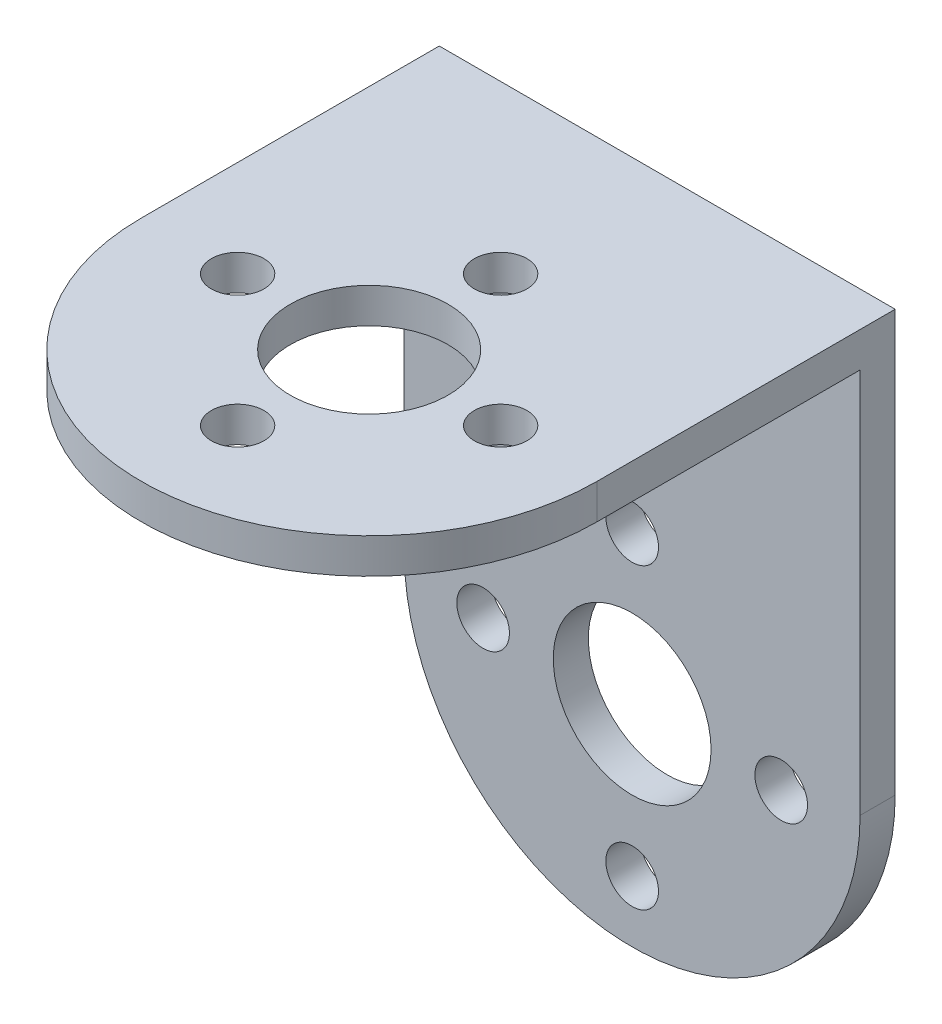
from build123d import *

# Parameters (mm, degrees)
BOSS_EXTRUDE1_DEPTH = 26
SKETCH4_R           = 4.5
SKETCH4_R_2         = 1.5
CUT_EXTRUDE2_DEPTH  = 3
SKETCH5_R           = 1.5
SKETCH5_R_2         = 4.5
CUT_EXTRUDE3_DEPTH  = 3


with BuildPart() as part:
    # Sketch2 → Boss-Extrude1 (new body)
    with BuildSketch(Plane(origin=(0, 0, 0), x_dir=(0, 0, -1), z_dir=(1, 0, 0))):
        Polygon((-15.5, 1), (14.5, 1), (14.5, -36), (12.5, -36), (12.5, -1), (-15.5, -1), align=None)
    extrude(amount=BOSS_EXTRUDE1_DEPTH)

    # Sketch4 → Cut-Extrude2 (cut, through all)
    with BuildSketch(Plane.XY.offset(-12.5)):
        with Locations((13, -24)):
            Circle(SKETCH4_R)
        with Locations((4.5, -24)):
            Circle(SKETCH4_R_2)
        with Locations((13, -32.5)):
            Circle(SKETCH4_R_2)
        with Locations((21.5, -24)):
            Circle(SKETCH4_R_2)
        with Locations((13, -15.5)):
            Circle(SKETCH4_R_2)
        with BuildLine():
            ThreePointArc((13, -36), (3.807611845, -32.192388155), (0, -23))
            Line((0, -23), (0, -36))
            Line((0, -36), (13, -36))
        make_face()
        with BuildLine():
            ThreePointArc((26, -23), (22.192388155, -32.192388155), (13, -36))
            Line((13, -36), (26, -36))
            Line((26, -36), (26, -23))
        make_face()
    extrude(amount=-CUT_EXTRUDE2_DEPTH, mode=Mode.SUBTRACT)

    # Sketch5 → Cut-Extrude3 (cut, through all)
    with BuildSketch(Plane.XZ.offset(1)):
        with Locations((5.5, 2.5)):
            Circle(SKETCH5_R)
        with Locations((13, -5)):
            Circle(SKETCH5_R)
        with Locations((13, 2.5)):
            Circle(SKETCH5_R_2)
        with Locations((20.5, 2.5)):
            Circle(SKETCH5_R)
        with BuildLine():
            Line((13, 15.5), (0, 15.5))
            Line((0, 15.5), (0, 2.5))
            ThreePointArc((0, 2.5), (3.807611845, 11.692388155), (13, 15.5))
        make_face()
        with BuildLine():
            Line((26, 15.5), (13, 15.5))
            ThreePointArc((13, 15.5), (22.192388155, 11.692388155), (26, 2.5))
            Line((26, 2.5), (26, 15.5))
        make_face()
        with Locations((13, 10)):
            Circle(SKETCH5_R)
    extrude(amount=-CUT_EXTRUDE3_DEPTH, mode=Mode.SUBTRACT)


solid = part.part
